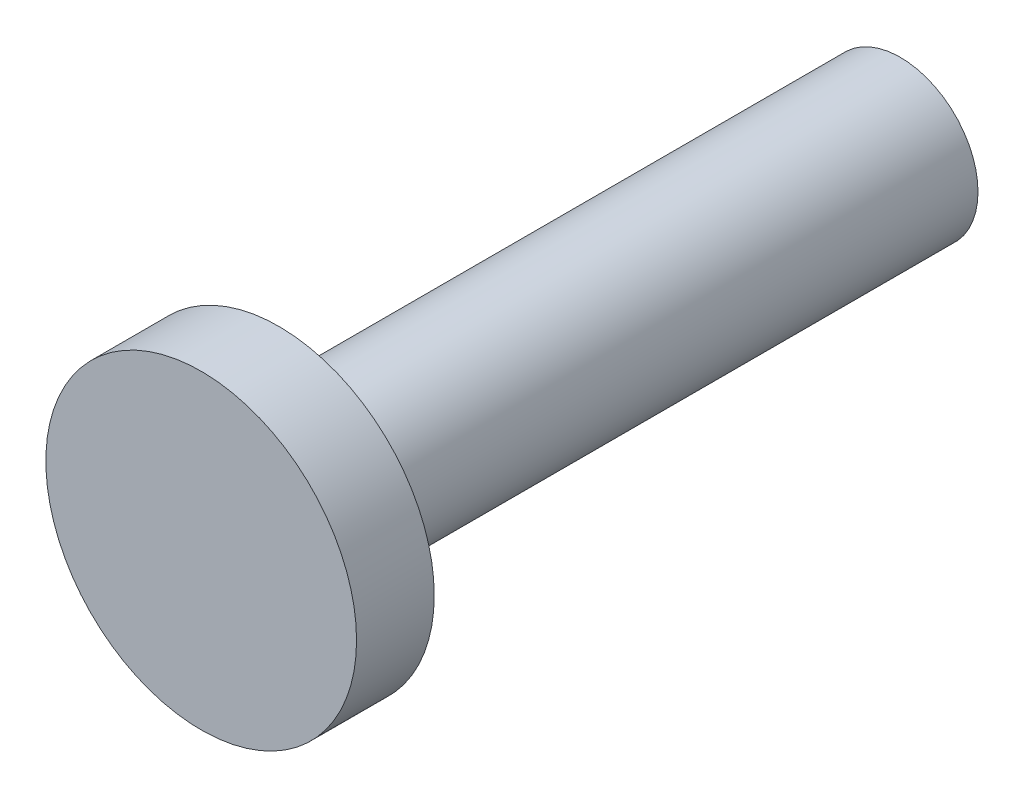
from build123d import *

# Parameters (mm, degrees)
SKETCH1_R           = 1
BOSS_EXTRUDE1_DEPTH = 8
SKETCH2_R           = 2
BOSS_EXTRUDE2_DEPTH = 1


with BuildPart() as part:
    # Sketch1 → Boss-Extrude1 (new body)
    with BuildSketch(Plane.XY):
        Circle(SKETCH1_R)
    extrude(amount=BOSS_EXTRUDE1_DEPTH)

    # Sketch2 → Boss-Extrude2 (add)
    with BuildSketch(Plane.XY.offset(8)):
        Circle(SKETCH2_R)
    extrude(amount=BOSS_EXTRUDE2_DEPTH)


solid = part.part
